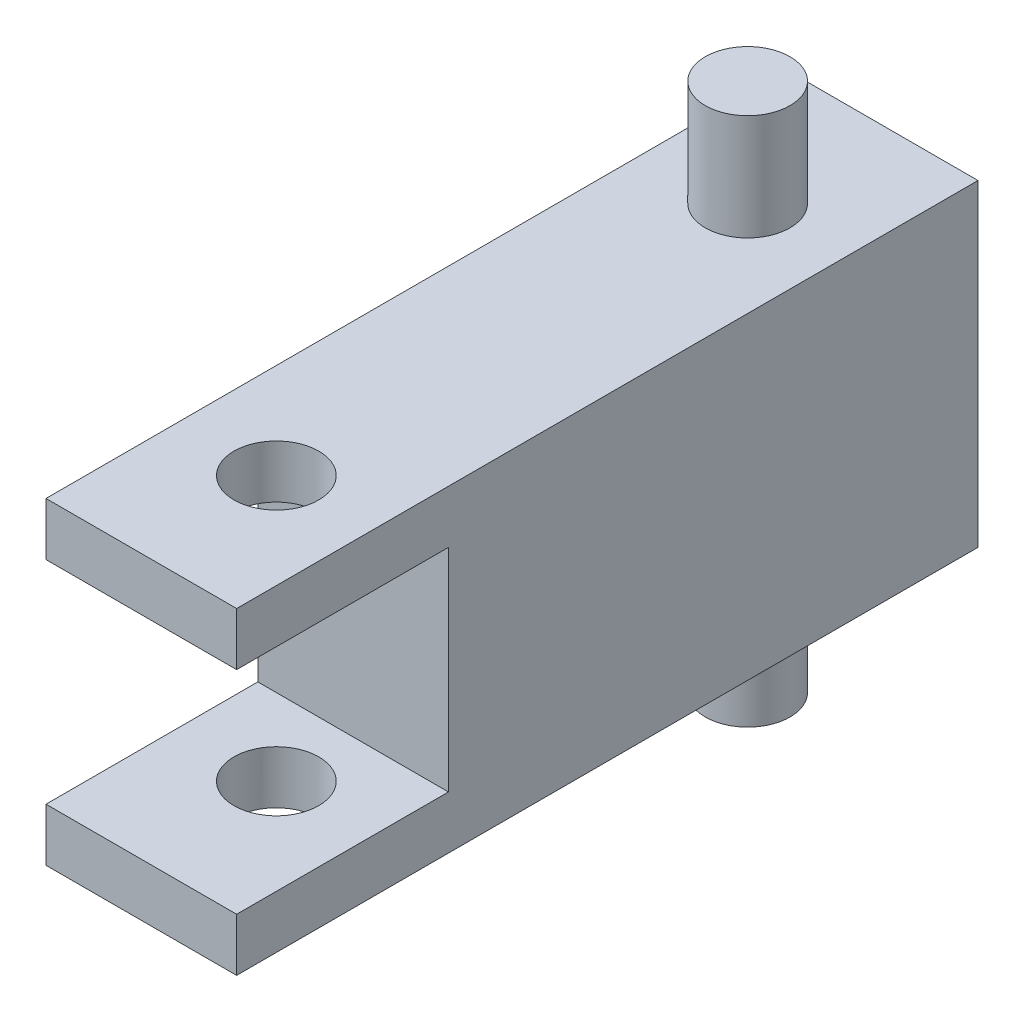
from build123d import *

# Parameters (mm, degrees)
ESQUISSE1_W             = 18
ESQUISSE1_H             = 30
BOSS_EXTRU_1_DEPTH      = 70
ESQUISSE2_R             = 4
BOSS_EXTRU_2_DEPTH      = 10
ESQUISSE3_R             = 4
ENL_V_MAT_EXTRU_1_DEPTH = 52
ESQUISSE4_W             = 20
ESQUISSE4_H             = 20
ENL_V_MAT_EXTRU_2_DEPTH = 52


with BuildPart() as part:
    # Esquisse1 → Boss.-Extru.1 (new body)
    with BuildSketch(Plane.XY):
        Rectangle(ESQUISSE1_W, ESQUISSE1_H)
    extrude(amount=BOSS_EXTRU_1_DEPTH)

    # Esquisse2 → Boss.-Extru.2 (add)
    with BuildSketch(Plane(origin=(0, 15, 0), x_dir=(1, 0, 0), z_dir=(0, 1, 0))):
        with Locations((0, -12.75)):
            Circle(ESQUISSE2_R)
    boss_extru_2 = extrude(amount=BOSS_EXTRU_2_DEPTH)

    # Symétrie1: Boss.-Extru.2 across plane
    add(boss_extru_2.mirror(Plane.ZX))

    # Symétrie2: Boss.-Extru.2 across plane
    add(boss_extru_2.mirror(Plane.XY.offset(35)))

    # Esquisse3 → Enlèv. mat.-Extru.1 (cut)
    with BuildSketch(Plane(origin=(0, 25, 0), x_dir=(1, 0, 0), z_dir=(0, 1, 0))):
        with Locations((0, -57.25)):
            Circle(ESQUISSE3_R)
    extrude(amount=-ENL_V_MAT_EXTRU_1_DEPTH, mode=Mode.SUBTRACT)

    # Esquisse4 → Enlèv. mat.-Extru.2 (cut)
    with BuildSketch(Plane(origin=(9, 0, 0), x_dir=(0, 0, -1), z_dir=(1, 0, 0))):
        with Locations((-60, 0)):
            Rectangle(ESQUISSE4_W, ESQUISSE4_H)
    extrude(amount=-ENL_V_MAT_EXTRU_2_DEPTH, mode=Mode.SUBTRACT)


solid = part.part
